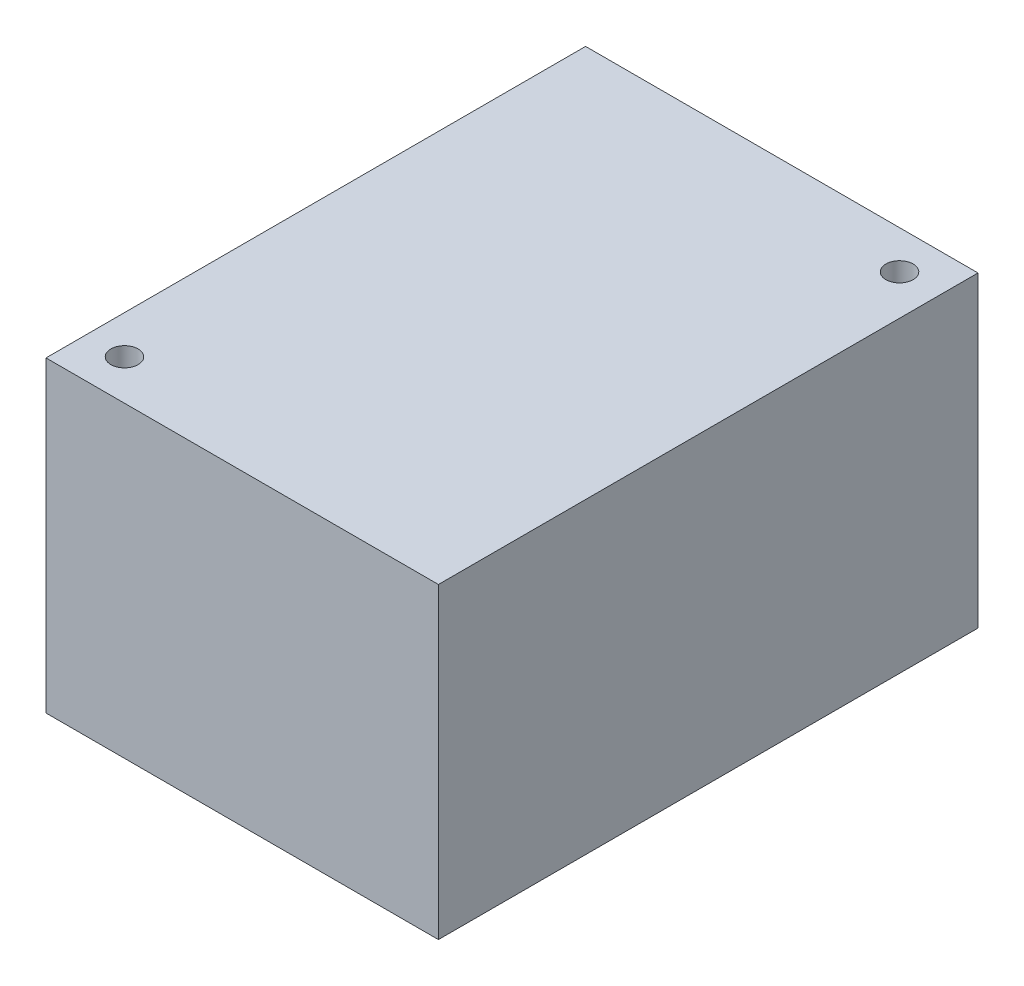
from build123d import *

# Parameters (mm, degrees)
BOSS_EXTRUDE1_START             = -14.3
SKETCH1_W                       = 40
SKETCH1_H                       = 55
BOSS_EXTRUDE1_DEPTH             = 31.35
F_7_64_0_10938_DIAMETER_HOLE1_D = 2.778252


with BuildPart() as part:
    # Sketch1 → Boss-Extrude1 (new body)
    with BuildSketch(Plane(origin=(0, 205.794413587, 0), x_dir=(1, 0, 0), z_dir=(0, 1, 0)).offset(BOSS_EXTRUDE1_START)):
        with Locations((59.936494412, -210.044134902)):
            Rectangle(SKETCH1_W, SKETCH1_H)
    extrude(amount=BOSS_EXTRUDE1_DEPTH)

    # 7/64 (0.10938) Diameter Hole1 (through all)
    with Locations(Plane(origin=(0, 191.494413587, 0), x_dir=(-1, 0, 0), z_dir=(0, -1, 0))):
        with Locations((-75.836494412, -186.444134902), (-43.836494412, -233.444134902)):
            Hole(F_7_64_0_10938_DIAMETER_HOLE1_D / 2)


solid = part.part
